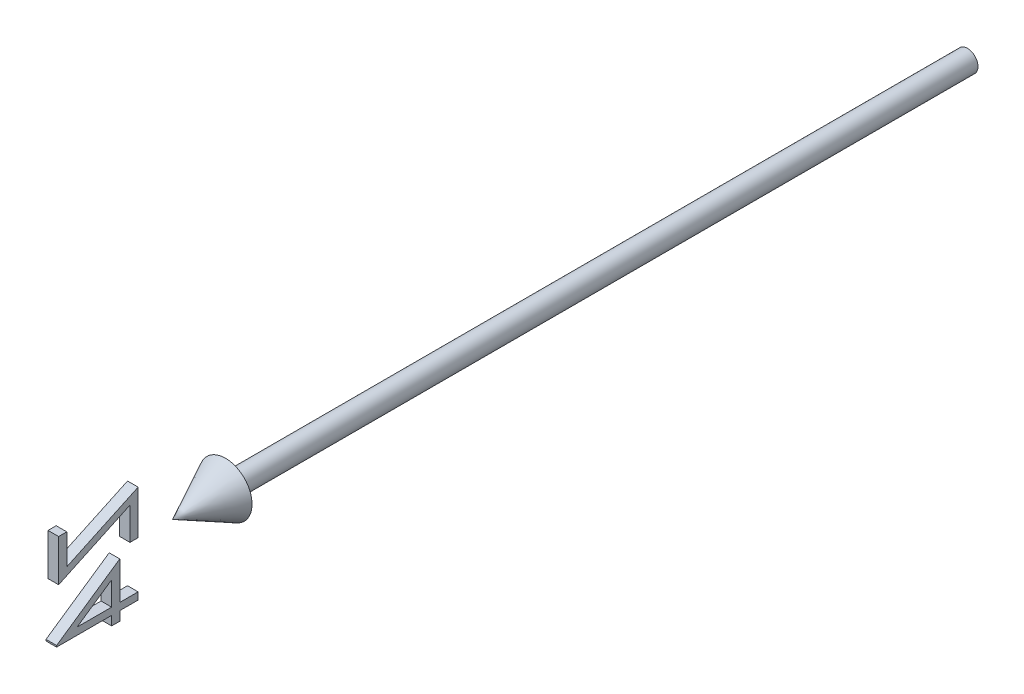
from build123d import *

# Parameters (mm, degrees)
BOSS_EXTRUDE1_DEPTH        = 1
BOSS_EXTRUDE1_DEPTH_BACK   = 1
BOSS_EXTRUDE1_2_DEPTH      = 1
BOSS_EXTRUDE1_2_DEPTH_BACK = 1


with BuildPart() as part:
    # Sketch2 → Revolve1 (revolve)
    with BuildSketch(Plane(origin=(0, 0, 0), x_dir=(1, 0, 0), z_dir=(0, 1, 0))):
        Polygon((0, -150), (5, -140), (2, -140), (2, 0), (0, 0), align=None)
    revolve(axis=Axis((0, 0, -41.949952025), (0, 0, 1)))


with BuildPart() as body_2:
    # Sketch3 → Boss-Extrude1 (new, two sides: drawn at the far end of the back side and taken through both)
    with BuildSketch(Plane(origin=(0, 0, 0), x_dir=(0, -1, 0), z_dir=(1, 0, 0)).offset(-BOSS_EXTRUDE1_DEPTH_BACK)):
        Polygon((-8.958586521, -170.961538462), (-8.958586521, -172.5), (-1.073971137, -172.5), (-7.366038444, -159.038461538), (-1.266278829, -159.038461538), (-1.266278829, -157.5), (-9.535509598, -157.5), (-3.243442291, -170.961538462), align=None)
    extrude(amount=BOSS_EXTRUDE1_DEPTH + BOSS_EXTRUDE1_DEPTH_BACK)


with BuildPart() as body_3:
    # Sketch3 → Boss-Extrude1 2 (new, two sides: drawn at the far end of the back side and taken through both)
    with BuildSketch(Plane(origin=(0, 0, 0), x_dir=(0, -1, 0), z_dir=(1, 0, 0)).offset(-BOSS_EXTRUDE1_2_DEPTH_BACK)):
        Polygon((8.652591363, -172.884615385), (8.926028863, -172.884615385), (8.926028863, -162.5), (10.656798094, -162.5), (10.656798094, -160.961538462), (8.926028863, -160.961538462), (8.926028863, -157.5), (7.579875017, -157.5), (7.579875017, -160.961538462), (0.464490402, -160.961538462), align=None)
        Polygon((7.579875017, -162.5), (7.579875017, -169.014423077), (3.108721171, -162.5), align=None, mode=Mode.SUBTRACT)
    extrude(amount=BOSS_EXTRUDE1_2_DEPTH + BOSS_EXTRUDE1_2_DEPTH_BACK)


solid = Compound([part.part, body_2.part, body_3.part])
